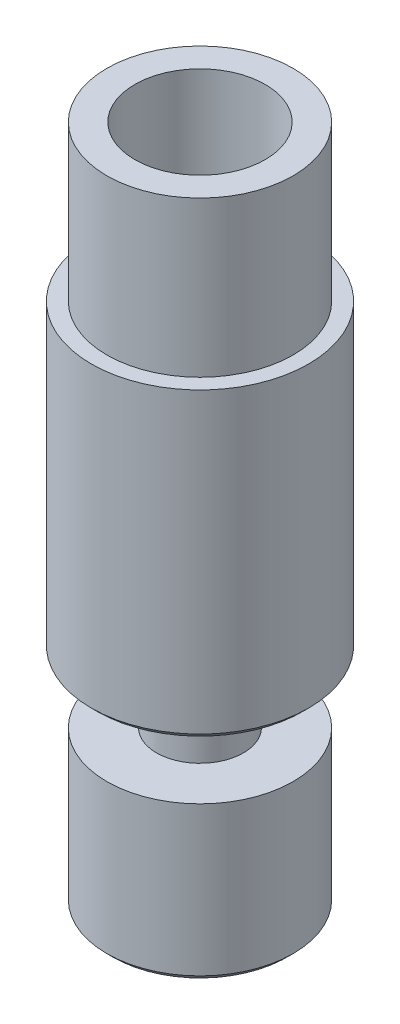
from build123d import *

# Parameters (mm, degrees)
CHAMFER1_SIZE = 0.2


with BuildPart() as part:
    # Sketch1 → Revolve1 (revolve)
    with BuildSketch(Plane.XY):
        Polygon((1, -10.95), (1, 5.314914704), (2.1, 5.95), (2.1, 10.95), (3, 10.95), (3, 5.95), (3.5, 5.95), (3.5, -3.85), (1.4, -3.85), (1.4, -5.95), (3, -5.95), (3, -10.95), align=None)
    revolve(axis=Axis((0, 10.95, 0), (0, -1, 0)))

    # Chamfer1
    chamfer1_edges = [part.edges().sort_by_distance(p)[0] for p in [
        (-3.5, -3.85, 0),
        (-1, -10.95, 0),
        (-3, -10.95, 0),
    ]]
    chamfer(chamfer1_edges, length=CHAMFER1_SIZE)


solid = part.part
